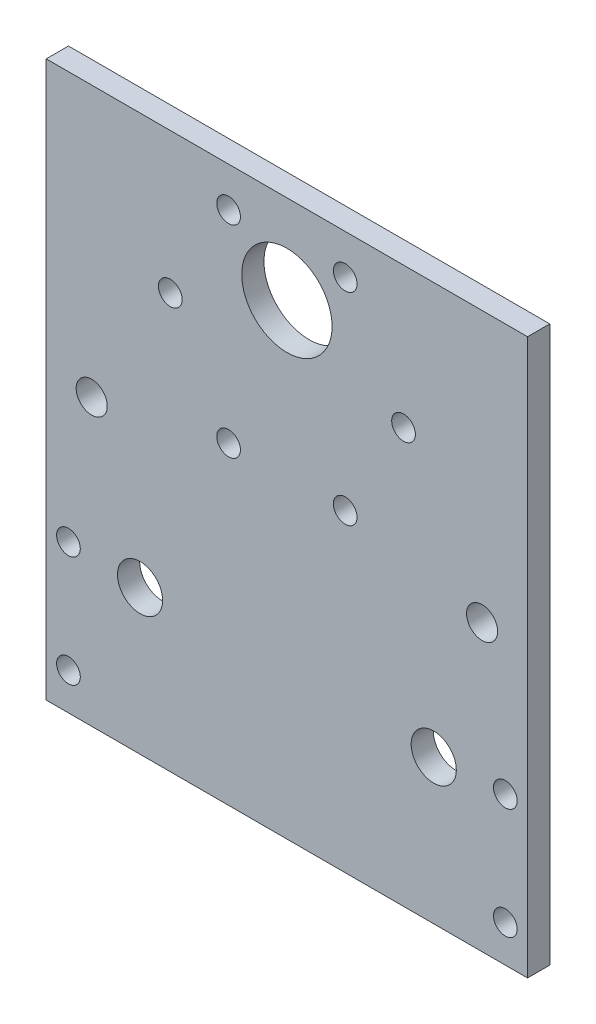
from build123d import *

# Parameters (mm, degrees)
SKETCH_1_W          = 65
SKETCH_1_H          = 25
SKETCH_1_R          = 3.05
EXTRUDE_1_DEPTH     = 3
CUT_EXTRUDE_1_DEPTH = 4
SKETCH_3_W          = 65
SKETCH_3_H          = 3
EXTRUDE_2_DEPTH     = 50
SKETCH_4_R          = 1.6
SKETCH_4_R_2        = 6.1
CUT_EXTRUDE_4_DEPTH = 40
SKETCH_5_R          = 2.1
CUT_EXTRUDE_5_DEPTH = 10
SKETCH_6_R          = 2.1
CUT_EXTRUDE_6_DEPTH = 10


with BuildPart() as part:
    # ｽｹｯﾁ1 → ﾎﾞｽ - 押し出し1 (new body)
    with BuildSketch(Plane.XY):
        Rectangle(SKETCH_1_W, SKETCH_1_H)
        with Locations((-19.83, 7)):
            Circle(SKETCH_1_R, mode=Mode.SUBTRACT)
        with Locations((19.83, 7)):
            Circle(SKETCH_1_R, mode=Mode.SUBTRACT)
    extrude(amount=EXTRUDE_1_DEPTH)

    # ｽｹｯﾁ2 → ｶｯﾄ - 押し出し1 (cut, through all)
    with BuildSketch(Plane.XY.offset(3)):
        with BuildLine():
            ThreePointArc((-27.9, 7.5), (-28.36862915, 8.63137085), (-29.5, 9.1))
            Line((-29.5, 9.1), (-29.5, 7.5))
            Line((-29.5, 7.5), (-31.1, 7.5))
            ThreePointArc((-31.1, 7.5), (-29.5, 5.9), (-27.9, 7.5))
        make_face()
        with BuildLine():
            Line((-29.5, 7.5), (-29.5, 9.1))
            ThreePointArc((-29.5, 9.1), (-30.63137085, 8.63137085), (-31.1, 7.5))
            Line((-31.1, 7.5), (-29.5, 7.5))
        make_face()
        with BuildLine():
            ThreePointArc((-31.1, -7.5), (-30.63137085, -8.63137085), (-29.5, -9.1))
            Line((-29.5, -9.1), (-29.5, -7.5))
            Line((-29.5, -7.5), (-31.1, -7.5))
        make_face()
        with BuildLine():
            Line((-29.5, -7.5), (-29.5, -9.1))
            ThreePointArc((-29.5, -9.1), (-28.36862915, -8.63137085), (-27.9, -7.5))
            ThreePointArc((-27.9, -7.5), (-29.5, -5.9), (-31.1, -7.5))
            Line((-31.1, -7.5), (-29.5, -7.5))
        make_face()
        with BuildLine():
            ThreePointArc((31.1, 7.5), (30.63137085, 8.63137085), (29.5, 9.1))
            Line((29.5, 9.1), (29.5, 7.5))
            Line((29.5, 7.5), (31.1, 7.5))
        make_face()
        with BuildLine():
            Line((29.5, 7.5), (29.5, 9.1))
            ThreePointArc((29.5, 9.1), (28.36862915, 6.36862915), (31.1, 7.5))
            Line((31.1, 7.5), (29.5, 7.5))
        make_face()
        with BuildLine():
            ThreePointArc((31.1, -7.5), (28.36862915, -6.36862915), (29.5, -9.1))
            Line((29.5, -9.1), (29.5, -7.5))
            Line((29.5, -7.5), (31.1, -7.5))
        make_face()
        with BuildLine():
            Line((29.5, -7.5), (29.5, -9.1))
            ThreePointArc((29.5, -9.1), (30.63137085, -8.63137085), (31.1, -7.5))
            Line((31.1, -7.5), (29.5, -7.5))
        make_face()
    extrude(amount=-CUT_EXTRUDE_1_DEPTH, mode=Mode.SUBTRACT)

    # ｽｹｯﾁ3 → ﾎﾞｽ - 押し出し2 (add)
    with BuildSketch(Plane(origin=(0, 12.5, 0), x_dir=(1, 0, 0), z_dir=(0, 1, 0))):
        with Locations((0, -1.5)):
            Rectangle(SKETCH_3_W, SKETCH_3_H)
    extrude(amount=EXTRUDE_2_DEPTH)

    # ｽｹｯﾁ4 → ｶｯﾄ - 押し出し4 (cut)
    with BuildSketch(Plane.XY):
        with Locations((-7.875, 57.13990011)):
            Circle(SKETCH_4_R)
        with Locations((7.875, 57.13990011)):
            Circle(SKETCH_4_R)
        with Locations((15.75, 43.5)):
            Circle(SKETCH_4_R)
        with Locations((7.875, 29.86009989)):
            Circle(SKETCH_4_R)
        with Locations((-7.875, 29.86009989)):
            Circle(SKETCH_4_R)
        with Locations((-15.75, 43.5)):
            Circle(SKETCH_4_R)
        with Locations((0, 50.5)):
            Circle(SKETCH_4_R_2)
    extrude(amount=CUT_EXTRUDE_4_DEPTH, mode=Mode.SUBTRACT)

    # ｽｹｯﾁ5 → ｶｯﾄ - 押し出し5 (cut)
    with BuildSketch(Plane(origin=(0, 0, 0), x_dir=(-1, 0, 0), z_dir=(0, 0, -1))):
        with Locations((-26.360896025, 26)):
            Circle(SKETCH_5_R)
    extrude(amount=-CUT_EXTRUDE_5_DEPTH, mode=Mode.SUBTRACT)

    # ｽｹｯﾁ6 → ｶｯﾄ - 押し出し6 (cut)
    with BuildSketch(Plane.XY.offset(3)):
        with Locations((-26.36, 26)):
            Circle(SKETCH_6_R)
    extrude(amount=-CUT_EXTRUDE_6_DEPTH, mode=Mode.SUBTRACT)


solid = part.part
